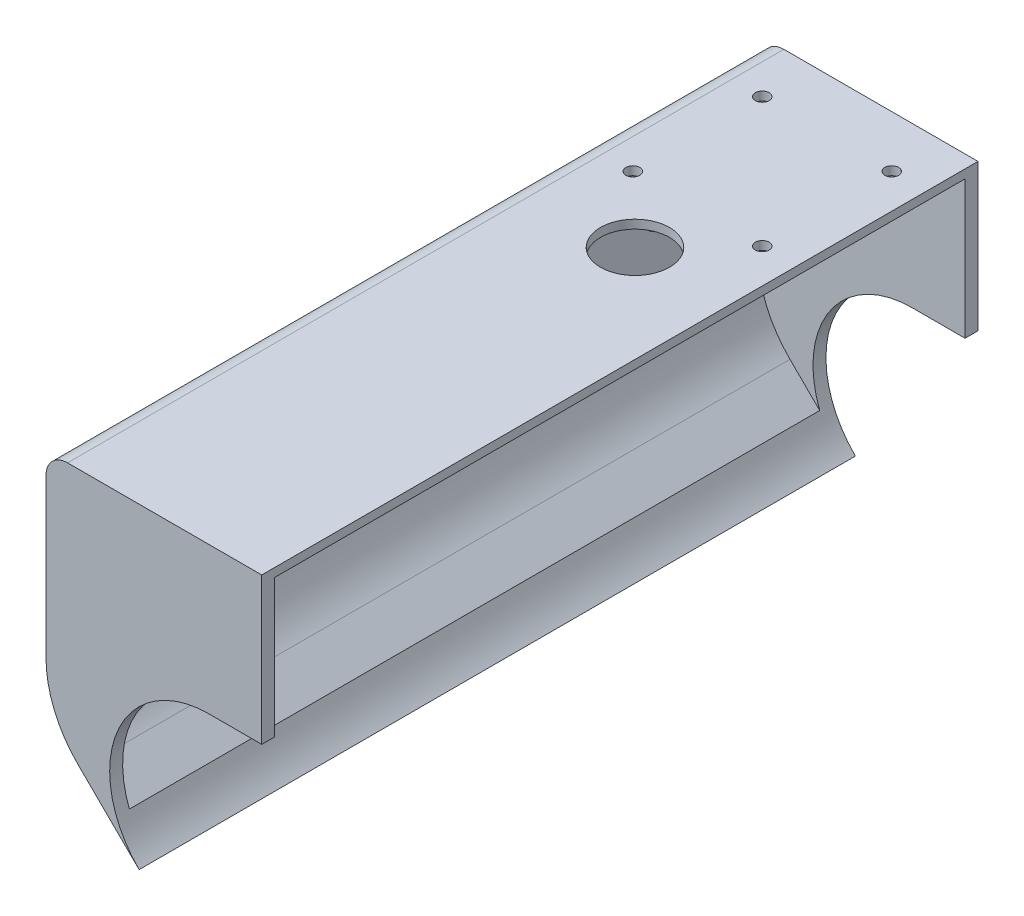
from build123d import *

# Parameters (mm, degrees)
BOSS_EXTRUDE1_DEPTH = 3
BOSS_EXTRUDE2_DEPTH = 3
BOSS_EXTRUDE3_DEPTH = 160
FILLET1_R           = 5
FILLET2_R           = 25
CUT_EXTRUDE1_DEPTH  = 5
SKETCH5_R           = 8
CUT_EXTRUDE2_DEPTH  = 2
SKETCH6_R           = 1.6
CUT_EXTRUDE3_DEPTH  = 2
SKETCH7_R           = 5
CUT_EXTRUDE4_DEPTH  = 3


with BuildPart() as part:
    # Sketch1 → Boss-Extrude1 (new body)
    with BuildSketch(Plane.XY):
        with BuildLine():
            Line((-176.422637822, 3.646230224), (-198.007283518, 24.991807553))
            Line((-198.007283518, 24.991807553), (-198.007283518, 77))
            Line((-198.007283518, 77), (-148.007283518, 77))
            Line((-148.007283518, 77), (-148.007283518, 43))
            Line((-148.007283518, 43), (-160.25, 43))
            ThreePointArc((-160.25, 43), (-181.523653951, 28.742519521), (-176.422637822, 3.646230224))
        make_face()
    extrude(amount=-BOSS_EXTRUDE1_DEPTH)



with BuildPart() as body_2:
    # Sketch2 → Boss-Extrude2 (new body)
    with BuildSketch(Plane(origin=(0, 0, -166), x_dir=(-1, 0, 0), z_dir=(0, 0, -1))):
        with BuildLine():
            Line((198.007283518, 24.991807553), (198.007283518, 77))
            Line((198.007283518, 77), (148.007283518, 77))
            Line((148.007283518, 77), (148.007283518, 43))
            Line((148.007283518, 43), (160.25, 43))
            ThreePointArc((160.25, 43), (181.523653951, 28.742519521), (176.422637822, 3.646230224))
            Line((176.422637822, 3.646230224), (198.007283518, 24.991807553))
        make_face()
    extrude(amount=-BOSS_EXTRUDE2_DEPTH)


with BuildPart() as part_1:
    add(part.part)

    add(body_2.part)  # Boss-Extrude3 merges body 2
    # Sketch3 → Boss-Extrude3 (add)
    with BuildSketch(Plane(origin=(0, 0, -3), x_dir=(-1, 0, 0), z_dir=(0, 0, -1))):
        with BuildLine():
            Line((181.686406663, 11.66450545), (196.007283518, 25.826766376))
            Line((196.007283518, 25.826766376), (196.007283518, 75))
            Line((196.007283518, 75), (148.007283518, 75))
            Line((148.007283518, 75), (148.007283518, 77))
            Line((148.007283518, 77), (198.007283518, 77))
            Line((198.007283518, 77), (198.007283518, 24.991807553))
            Line((198.007283518, 24.991807553), (176.422637822, 3.646230224))
            ThreePointArc((176.422637822, 3.646230224), (179.477148545, 7.377925731), (181.686406663, 11.66450545))
        make_face()
    extrude(amount=BOSS_EXTRUDE3_DEPTH)

    # Fillet1
    fillet1_edges = [part_1.edges().sort_by_distance(p)[0] for p in [
        (-198.007283518, 77, -83),
        (-196.007283518, 75, -83),
    ]]
    fillet(fillet1_edges, radius=FILLET1_R)

    # Fillet2
    fillet2_edges = [part_1.edges().sort_by_distance(p)[0] for p in [
        (-198.007283518, 24.991807553, -83),
        (-196.007283518, 25.826766376, -83),
    ]]
    fillet(fillet2_edges, radius=FILLET2_R)

    # Sketch4 → Cut-Extrude1 (cut)
    with BuildSketch(Plane.ZY.offset(198.007283518)):
        with BuildLine():
            Line((-112, 59.5), (-54, 59.5))
            ThreePointArc((-54, 59.5), (-53.292893219, 59.207106781), (-53, 58.5))
            Line((-53, 58.5), (-53, 57.5))
            ThreePointArc((-53, 57.5), (-53.292893219, 56.792893219), (-54, 56.5))
            Line((-54, 56.5), (-112, 56.5))
            ThreePointArc((-112, 56.5), (-112.707106781, 56.792893219), (-113, 57.5))
            Line((-113, 57.5), (-113, 58.5))
            ThreePointArc((-113, 58.5), (-112.707106781, 59.207106781), (-112, 59.5))
        make_face()
        with BuildLine():
            Line((-112, 67), (-54, 67))
            ThreePointArc((-54, 67), (-53.292893219, 66.707106781), (-53, 66))
            Line((-53, 66), (-53, 65))
            ThreePointArc((-53, 65), (-53.292893219, 64.292893219), (-54, 64))
            Line((-54, 64), (-112, 64))
            ThreePointArc((-112, 64), (-112.707106781, 64.292893219), (-113, 65))
            Line((-113, 65), (-113, 66))
            ThreePointArc((-113, 66), (-112.707106781, 66.707106781), (-112, 67))
        make_face()
        with BuildLine():
            Line((-112, 52), (-54, 52))
            ThreePointArc((-54, 52), (-53.292893219, 51.707106781), (-53, 51))
            Line((-53, 51), (-53, 50))
            ThreePointArc((-53, 50), (-53.292893219, 49.292893219), (-54, 49))
            Line((-54, 49), (-112, 49))
            ThreePointArc((-112, 49), (-112.707106781, 49.292893219), (-113, 50))
            Line((-113, 50), (-113, 51))
            ThreePointArc((-113, 51), (-112.707106781, 51.707106781), (-112, 52))
        make_face()
        with BuildLine():
            Line((-112, 44.5), (-54, 44.5))
            ThreePointArc((-54, 44.5), (-53.292893219, 44.207106781), (-53, 43.5))
            Line((-53, 43.5), (-53, 42.5))
            ThreePointArc((-53, 42.5), (-53.292893219, 41.792893219), (-54, 41.5))
            Line((-54, 41.5), (-112, 41.5))
            ThreePointArc((-112, 41.5), (-112.707106781, 41.792893219), (-113, 42.5))
            Line((-113, 42.5), (-113, 43.5))
            ThreePointArc((-113, 43.5), (-112.707106781, 44.207106781), (-112, 44.5))
        make_face()
    extrude(amount=-CUT_EXTRUDE1_DEPTH, mode=Mode.SUBTRACT)

    # Sketch5 → Cut-Extrude2 (cut)
    with BuildSketch(Plane(origin=(0, 77, 0), x_dir=(1, 0, 0), z_dir=(0, 1, 0))):
        with Locations((-170.507283518, 109)):
            Circle(SKETCH5_R)
    extrude(amount=-CUT_EXTRUDE2_DEPTH, mode=Mode.SUBTRACT)

    # Sketch6 → Cut-Extrude3 (cut)
    with BuildSketch(Plane(origin=(0, 77, 0), x_dir=(1, 0, 0), z_dir=(0, 1, 0))):
        with Locations((-156.007283518, 154)):
            Circle(SKETCH6_R)
        with Locations((-156.007283518, 124)):
            Circle(SKETCH6_R)
        with Locations((-186.007283518, 124)):
            Circle(SKETCH6_R)
        with Locations((-186.007283518, 154)):
            Circle(SKETCH6_R)
    extrude(amount=-CUT_EXTRUDE3_DEPTH, mode=Mode.SUBTRACT)

    # Sketch7 → Cut-Extrude4 (cut)
    with BuildSketch(Plane.ZY.offset(198.007283518)):
        with Locations((-141, 57)):
            Circle(SKETCH7_R)
    extrude(amount=-CUT_EXTRUDE4_DEPTH, mode=Mode.SUBTRACT)


solid = part_1.part
